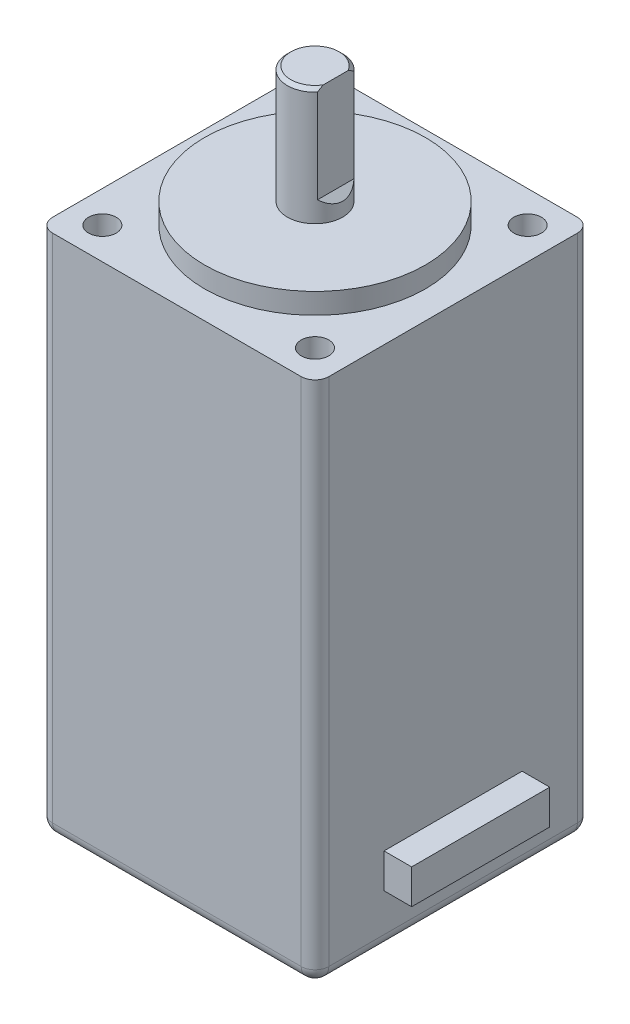
from build123d import *

# Parameters (mm, degrees)
SKETCH1_W               = 20
SKETCH1_H               = 20
BOSS_EXTRUDE1_DEPTH     = 38
SKETCH2_R               = 1
CUT_EXTRUDE1_DEPTH      = 2.5
SKETCH3_R               = 8
BOSS_EXTRUDE2_DEPTH     = 1.5
SKETCH4_R               = 2
BOSS_EXTRUDE3_DEPTH     = 10
CUT_EXTRUDE2_DEPTH      = 11
CUT_EXTRUDE2_DEPTH_BACK = 11
CHAMFER1_SIZE           = 0.25
FILLET1_R               = 1
SKETCH6_W               = 10
SKETCH6_H               = 2.5
BOSS_EXTRUDE4_DEPTH     = 12


with BuildPart() as part:
    # Sketch1 → Boss-Extrude1 (new body)
    with BuildSketch(Plane(origin=(0, 0, 0), x_dir=(1, 0, 0), z_dir=(0, 1, 0))):
        Rectangle(SKETCH1_W, SKETCH1_H)
    extrude(amount=-BOSS_EXTRUDE1_DEPTH)

    # Sketch2 → Cut-Extrude1 (cut)
    with BuildSketch(Plane(origin=(0, 0, 0), x_dir=(1, 0, 0), z_dir=(0, 1, 0))):
        with Locations((-7.7, 7.7)):
            Circle(SKETCH2_R)
        with Locations((7.7, 7.7)):
            Circle(SKETCH2_R)
        with Locations((7.7, -7.7)):
            Circle(SKETCH2_R)
        with Locations((-7.7, -7.7)):
            Circle(SKETCH2_R)
    extrude(amount=-CUT_EXTRUDE1_DEPTH, mode=Mode.SUBTRACT)

    # Sketch3 → Boss-Extrude2 (add)
    with BuildSketch(Plane(origin=(0, 0, 0), x_dir=(1, 0, 0), z_dir=(0, 1, 0))):
        Circle(SKETCH3_R)
    extrude(amount=BOSS_EXTRUDE2_DEPTH)

    # Sketch4 → Boss-Extrude3 (add)
    with BuildSketch(Plane(origin=(0, 0, 0), x_dir=(1, 0, 0), z_dir=(0, 1, 0))):
        Circle(SKETCH4_R)
    extrude(amount=BOSS_EXTRUDE3_DEPTH)

    # Sketch5 → Cut-Extrude2 (cut, two sides)
    with BuildSketch(Plane.XY) as cut_extrude2_sk:
        Polygon((2, 10), (1.5, 10), (1.5, 3), (2, 2.5), align=None)
    extrude(amount=CUT_EXTRUDE2_DEPTH, mode=Mode.SUBTRACT)
    extrude(cut_extrude2_sk.sketch, amount=-CUT_EXTRUDE2_DEPTH_BACK, mode=Mode.SUBTRACT)

    # Chamfer1
    chamfer1_edges = [part.edges().sort_by_distance(p)[0] for p in [
        (-2, 10, 0),
    ]]
    chamfer(chamfer1_edges, length=CHAMFER1_SIZE)

    # Fillet1
    fillet1_edges = [part.edges().sort_by_distance(p)[0] for p in [
        (10, -38, 0),
        (0, -38, -10),
        (-10, -38, 0),
        (0, -38, 10),
        (-10, -19, -10),
        (10, -19, -10),
        (10, -19, 10),
        (-10, -19, 10),
    ]]
    fillet(fillet1_edges, radius=FILLET1_R)

    # Sketch6 → Boss-Extrude4 (add)
    with BuildSketch(Plane(origin=(0, 0, 0), x_dir=(0, 0, -1), z_dir=(1, 0, 0))):
        with Locations((0, -33)):
            Rectangle(SKETCH6_W, SKETCH6_H)
    extrude(amount=BOSS_EXTRUDE4_DEPTH)


solid = part.part
